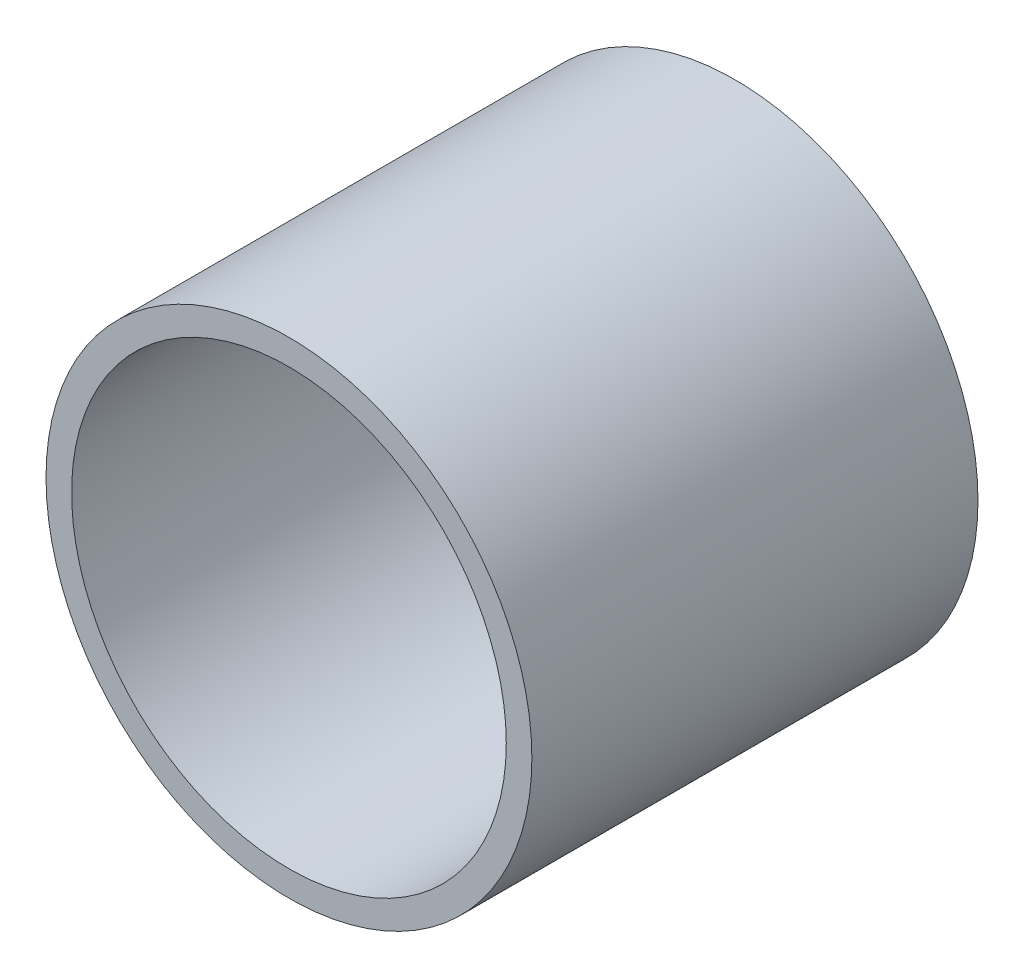
from build123d import *

# Parameters (mm, degrees)
SKETCH1_R           = 57.15
SKETCH1_R_2         = 51.1302
EXTRUDE_THIN1_DEPTH = 52.475


with BuildPart() as part:
    # Sketch1 → Extrude-Thin1 (new body, symmetric)
    with BuildSketch(Plane.XY):
        Circle(SKETCH1_R)
        Circle(SKETCH1_R_2, mode=Mode.SUBTRACT)
    extrude(amount=EXTRUDE_THIN1_DEPTH, both=True)


solid = part.part
